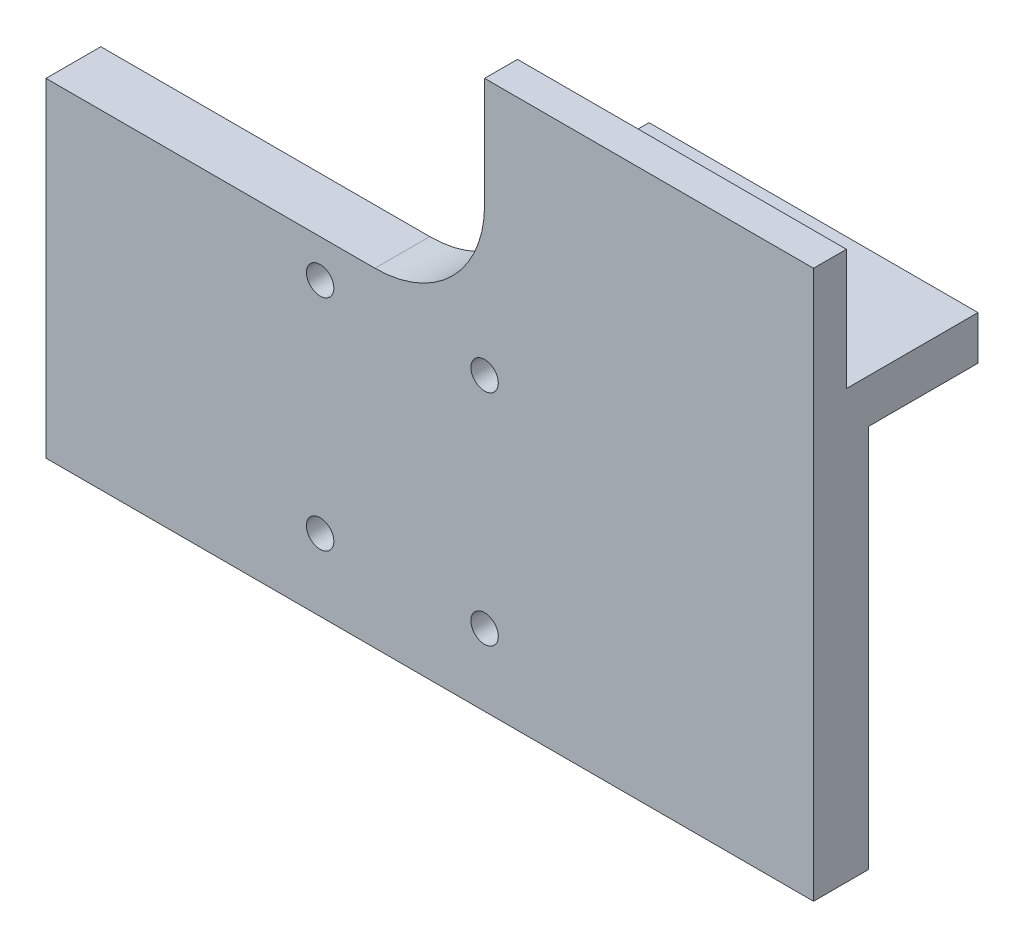
from build123d import *

# Parameters (mm, degrees)
BODY_DEPTH           = 5
LPATTERN1_COUNT      = 2
LPATTERN1_PITCH      = 15
LPATTERN1_COUNT_DIR2 = 2
LPATTERN1_PITCH_DIR2 = 20
SKETCH4_W            = 30
SKETCH4_H            = 2
CUT_EXTRUDE2_DEPTH   = 12
SKETCH5_W            = 30
SKETCH5_H            = 1
BOSS_EXTRUDE3_DEPTH  = 12
SKETCH6_W            = 30
SKETCH6_H            = 10
BOSS_EXTRUDE4_DEPTH  = 3


with BuildPart() as part:
    # Sketch1 → Body (new body)
    with BuildSketch(Plane.XY):
        with BuildLine():
            Line((0, 0), (70, 0))
            Line((70, 0), (70, 50))
            Line((70, 50), (40, 50))
            Line((40, 50), (40, 40))
            ThreePointArc((40, 40), (37.071067812, 32.928932188), (30, 30))
            Line((30, 30), (0, 30))
            Line((0, 30), (0, 0))
        make_face()
    extrude(amount=BODY_DEPTH)

    # Sketch8 → M3x0.5 Tapped Hole1 (revolve, cut)
    with BuildSketch(Plane(origin=(25, 6.55, 5), x_dir=(0, -1, 0), z_dir=(1, 0, 0))):
        Polygon((0, 0), (0, 5), (1.525, 5), (1.25, 4.725), (1.25, 0), align=None)
    m3x0_5_tapped_hole1 = revolve(axis=Axis((25, 6.55, 11.35), (0, 0, -1)), mode=Mode.SUBTRACT)

    # LPattern1: M3x0.5 Tapped Hole1 2 × 2
    with Locations(*[(i * LPATTERN1_PITCH, j * LPATTERN1_PITCH_DIR2, 0) for i in range(LPATTERN1_COUNT) for j in range(LPATTERN1_COUNT_DIR2) if (i, j) != (0, 0)]):
        add(m3x0_5_tapped_hole1, mode=Mode.SUBTRACT)

    # Sketch4 → Cut-Extrude2 (cut)
    with BuildSketch(Plane(origin=(0, 50, 0), x_dir=(1, 0, 0), z_dir=(0, 1, 0))):
        with Locations((55, -1)):
            Rectangle(SKETCH4_W, SKETCH4_H)
    extrude(amount=-CUT_EXTRUDE2_DEPTH, mode=Mode.SUBTRACT)

    # Sketch5 → Boss-Extrude3 (add)
    with BuildSketch(Plane(origin=(0, 0, 2), x_dir=(-1, 0, 0), z_dir=(0, 0, -1))):
        with Locations((-55, 38.5)):
            Rectangle(SKETCH5_W, SKETCH5_H)
    extrude(amount=BOSS_EXTRUDE3_DEPTH)

    # Sketch6 → Boss-Extrude4 (add)
    with BuildSketch(Plane.XZ.offset(-38)):
        with Locations((55, -5)):
            Rectangle(SKETCH6_W, SKETCH6_H)
    extrude(amount=BOSS_EXTRUDE4_DEPTH)


solid = part.part
